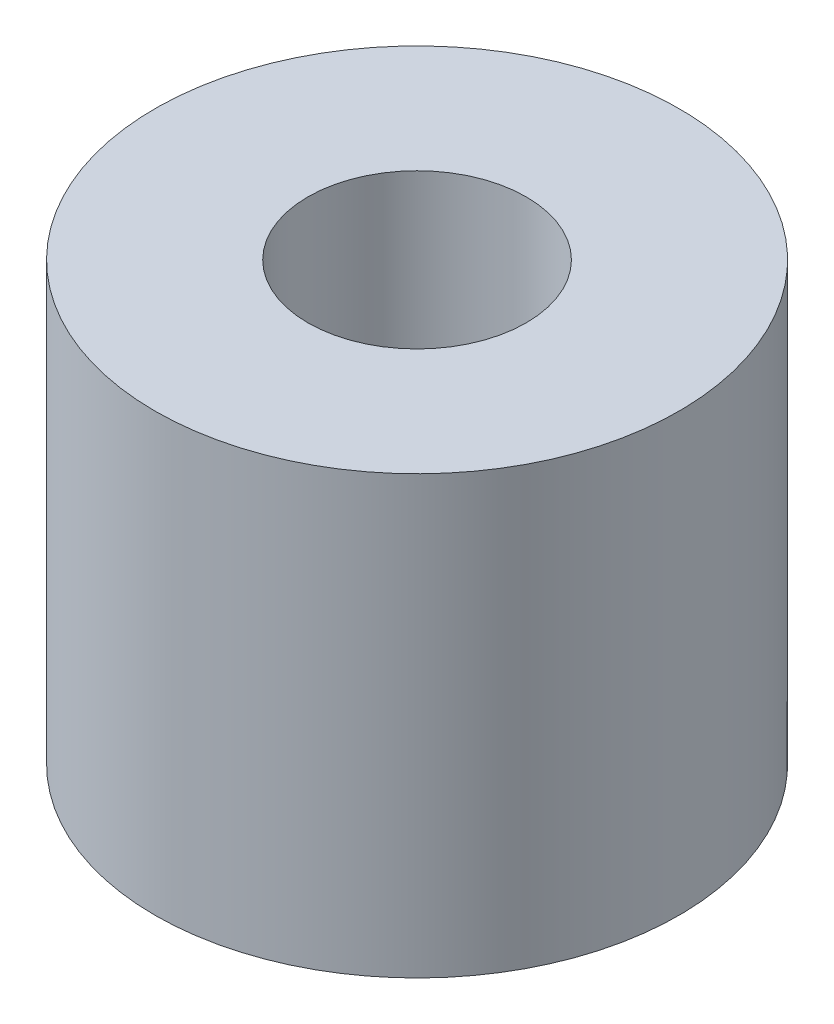
from build123d import *

# Parameters (mm, degrees)
SKETCH1_R           = 3.81
SKETCH1_R_2         = 1.5875
BOSS_EXTRUDE1_DEPTH = 6.35


with BuildPart() as part:
    # Sketch1 → Boss-Extrude1 (new body)
    with BuildSketch(Plane(origin=(0, 0, 0), x_dir=(1, 0, 0), z_dir=(0, 1, 0))):
        Circle(SKETCH1_R)
        Circle(SKETCH1_R_2, mode=Mode.SUBTRACT)
    extrude(amount=BOSS_EXTRUDE1_DEPTH)


solid = part.part
